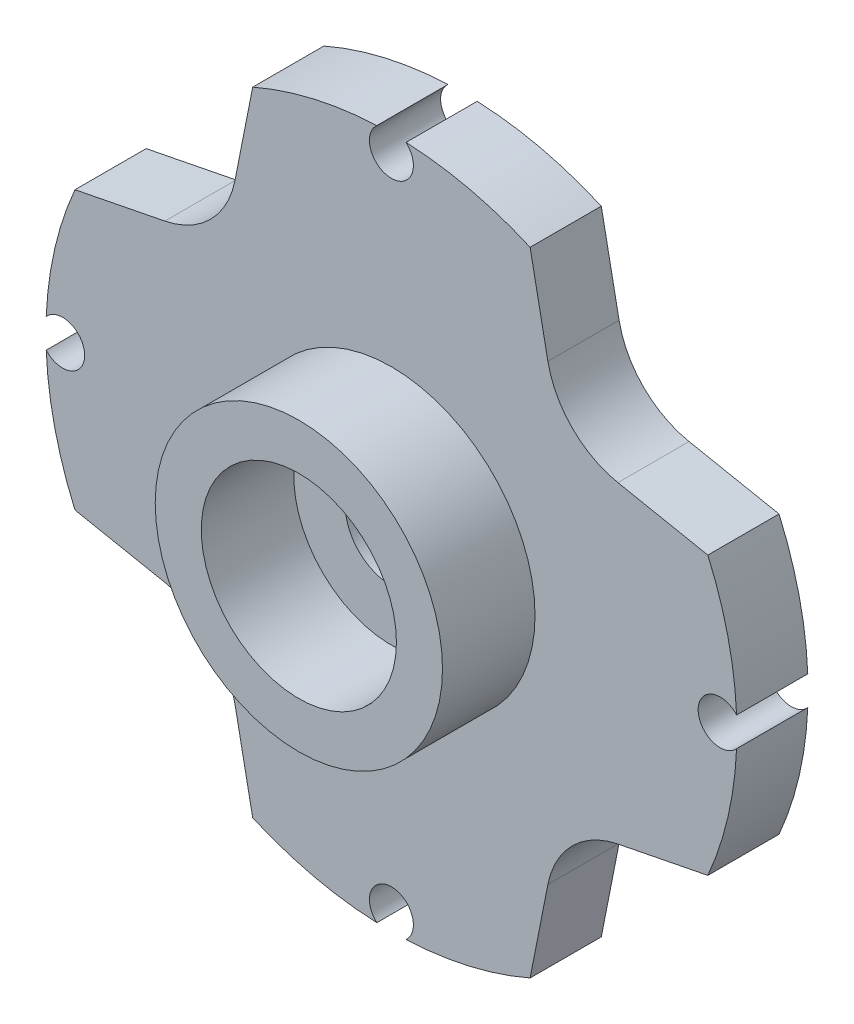
from build123d import *

# Parameters (mm, degrees)
BOSS_EXTRUDE1_DEPTH     = 1.7
CUT_EXTRUDE1_REACH      = 3.7
SKETCH2_R               = 1.1
SKETCH3_R               = 3.43
SKETCH3_R_2             = 2.33
BOSS_EXTRUDE2_DEPTH     = 2.21
SKETCH4_R               = 3.5
SKETCH4_R_2             = 2.95
BOSS_EXTRUDE3_DEPTH     = 0.51
SKETCH5_R               = 2.95
CUT_EXTRUDE2_DEPTH      = 1.1
CUT_EXTRUDE3_REACH      = 4.21
SKETCH6_R               = 0.525
SKETCH7_R               = 18.883041925
SKETCH7_R_2             = 8.25
CUT_EXTRUDE4_DEPTH      = 3.21
CUT_EXTRUDE4_DEPTH_BACK = 3.21


with BuildPart() as part:
    # Sketch1 → Boss-Extrude1 (new body)
    with BuildSketch(Plane.XY):
        with BuildLine():
            Line((5.409077957, 3.736708277), (13.762285951, 2.084772448))
            ThreePointArc((13.762285951, 2.084772448), (15.475148434, 0), (13.762285951, -2.084772448))
            Line((13.762285951, -2.084772448), (5.409077957, -3.736708277))
            ThreePointArc((5.409077957, -3.736708277), (4.318733201, -4.318733201), (3.736708277, -5.409077957))
            Line((3.736708277, -5.409077957), (2.084772448, -13.762285951))
            ThreePointArc((2.084772448, -13.762285951), (0, -15.475148434), (-2.084772448, -13.762285951))
            Line((-2.084772448, -13.762285951), (-3.736708277, -5.409077957))
            ThreePointArc((-3.736708277, -5.409077957), (-4.318733201, -4.318733201), (-5.409077957, -3.736708277))
            Line((-5.409077957, -3.736708277), (-13.762285951, -2.084772448))
            ThreePointArc((-13.762285951, -2.084772448), (-15.475148434, 0), (-13.762285951, 2.084772448))
            Line((-13.762285951, 2.084772448), (-5.409077957, 3.736708277))
            ThreePointArc((-5.409077957, 3.736708277), (-4.318733201, 4.318733201), (-3.736708277, 5.409077957))
            Line((-3.736708277, 5.409077957), (-2.084772448, 13.762285951))
            ThreePointArc((-2.084772448, 13.762285951), (0, 15.475148434), (2.084772448, 13.762285951))
            Line((2.084772448, 13.762285951), (3.736708277, 5.409077957))
            ThreePointArc((3.736708277, 5.409077957), (4.318733201, 4.318733201), (5.409077957, 3.736708277))
        make_face()
    extrude(amount=BOSS_EXTRUDE1_DEPTH)

    # Sketch2 → Cut-Extrude1 (cut, up to next)
    with BuildSketch(Plane.XY.offset(1.7), mode=Mode.PRIVATE) as cut_extrude1_sk1:
        Circle(SKETCH2_R)
    cut_extrude1_tool1 = extrude(cut_extrude1_sk1.sketch, amount=-CUT_EXTRUDE1_REACH, mode=Mode.PRIVATE) & part.part
    add(cut_extrude1_tool1.solids().sort_by_distance((0, 0, 1.7))[0], mode=Mode.SUBTRACT)

    # Sketch3 → Boss-Extrude2 (add)
    with BuildSketch(Plane.XY.offset(1.7)):
        Circle(SKETCH3_R)
        Circle(SKETCH3_R_2, mode=Mode.SUBTRACT)
    extrude(amount=BOSS_EXTRUDE2_DEPTH)

    # Sketch4 → Boss-Extrude3 (add)
    with BuildSketch(Plane(origin=(0, 0, 0), x_dir=(-1, 0, 0), z_dir=(0, 0, -1))):
        Circle(SKETCH4_R)
        Circle(SKETCH4_R_2, mode=Mode.SUBTRACT)
    extrude(amount=BOSS_EXTRUDE3_DEPTH)

    # Sketch5 → Cut-Extrude2 (cut)
    with BuildSketch(Plane(origin=(0, 0, -0.51), x_dir=(-1, 0, 0), z_dir=(0, 0, -1))):
        Circle(SKETCH5_R)
    extrude(amount=-CUT_EXTRUDE2_DEPTH, mode=Mode.SUBTRACT)

    # Sketch6 → Cut-Extrude3 (cut, up to next)
    with BuildSketch(Plane.XY.offset(1.7), mode=Mode.PRIVATE) as cut_extrude3_sk1:
        with Locations((0, 13.35)):
            Circle(SKETCH6_R)
    cut_extrude3_tool1 = extrude(cut_extrude3_sk1.sketch, amount=-CUT_EXTRUDE3_REACH, mode=Mode.PRIVATE) & part.part
    add(cut_extrude3_tool1.solids().sort_by_distance((0, 13.35, 1.7))[0], mode=Mode.SUBTRACT)
    # Sketch6 → Cut-Extrude3 (cut, up to next)
    with BuildSketch(Plane.XY.offset(1.7), mode=Mode.PRIVATE) as cut_extrude3_sk2:
        with Locations((0, 10.6)):
            Circle(SKETCH6_R)
    cut_extrude3_tool2 = extrude(cut_extrude3_sk2.sketch, amount=-CUT_EXTRUDE3_REACH, mode=Mode.PRIVATE) & part.part
    add(cut_extrude3_tool2.solids().sort_by_distance((0, 10.6, 1.7))[0], mode=Mode.SUBTRACT)
    # Sketch6 → Cut-Extrude3 (cut, up to next)
    with BuildSketch(Plane.XY.offset(1.7), mode=Mode.PRIVATE) as cut_extrude3_sk3:
        with Locations((0, 7.85)):
            Circle(SKETCH6_R)
    cut_extrude3_tool3 = extrude(cut_extrude3_sk3.sketch, amount=-CUT_EXTRUDE3_REACH, mode=Mode.PRIVATE) & part.part
    add(cut_extrude3_tool3.solids().sort_by_distance((0, 7.85, 1.7))[0], mode=Mode.SUBTRACT)
    # Sketch6 → Cut-Extrude3 (cut, up to next)
    with BuildSketch(Plane.XY.offset(1.7), mode=Mode.PRIVATE) as cut_extrude3_sk4:
        with Locations((13.35, 0)):
            Circle(SKETCH6_R)
    cut_extrude3_tool4 = extrude(cut_extrude3_sk4.sketch, amount=-CUT_EXTRUDE3_REACH, mode=Mode.PRIVATE) & part.part
    add(cut_extrude3_tool4.solids().sort_by_distance((13.35, 0, 1.7))[0], mode=Mode.SUBTRACT)
    # Sketch6 → Cut-Extrude3 (cut, up to next)
    with BuildSketch(Plane.XY.offset(1.7), mode=Mode.PRIVATE) as cut_extrude3_sk5:
        with Locations((10.6, 0)):
            Circle(SKETCH6_R)
    cut_extrude3_tool5 = extrude(cut_extrude3_sk5.sketch, amount=-CUT_EXTRUDE3_REACH, mode=Mode.PRIVATE) & part.part
    add(cut_extrude3_tool5.solids().sort_by_distance((10.6, 0, 1.7))[0], mode=Mode.SUBTRACT)
    # Sketch6 → Cut-Extrude3 (cut, up to next)
    with BuildSketch(Plane.XY.offset(1.7), mode=Mode.PRIVATE) as cut_extrude3_sk6:
        with Locations((7.85, 0)):
            Circle(SKETCH6_R)
    cut_extrude3_tool6 = extrude(cut_extrude3_sk6.sketch, amount=-CUT_EXTRUDE3_REACH, mode=Mode.PRIVATE) & part.part
    add(cut_extrude3_tool6.solids().sort_by_distance((7.85, 0, 1.7))[0], mode=Mode.SUBTRACT)
    # Sketch6 → Cut-Extrude3 (cut, up to next)
    with BuildSketch(Plane.XY.offset(1.7), mode=Mode.PRIVATE) as cut_extrude3_sk7:
        with Locations((0, -13.35)):
            Circle(SKETCH6_R)
    cut_extrude3_tool7 = extrude(cut_extrude3_sk7.sketch, amount=-CUT_EXTRUDE3_REACH, mode=Mode.PRIVATE) & part.part
    add(cut_extrude3_tool7.solids().sort_by_distance((0, -13.35, 1.7))[0], mode=Mode.SUBTRACT)
    # Sketch6 → Cut-Extrude3 (cut, up to next)
    with BuildSketch(Plane.XY.offset(1.7), mode=Mode.PRIVATE) as cut_extrude3_sk8:
        with Locations((0, -10.6)):
            Circle(SKETCH6_R)
    cut_extrude3_tool8 = extrude(cut_extrude3_sk8.sketch, amount=-CUT_EXTRUDE3_REACH, mode=Mode.PRIVATE) & part.part
    add(cut_extrude3_tool8.solids().sort_by_distance((0, -10.6, 1.7))[0], mode=Mode.SUBTRACT)
    # Sketch6 → Cut-Extrude3 (cut, up to next)
    with BuildSketch(Plane.XY.offset(1.7), mode=Mode.PRIVATE) as cut_extrude3_sk9:
        with Locations((0, -7.85)):
            Circle(SKETCH6_R)
    cut_extrude3_tool9 = extrude(cut_extrude3_sk9.sketch, amount=-CUT_EXTRUDE3_REACH, mode=Mode.PRIVATE) & part.part
    add(cut_extrude3_tool9.solids().sort_by_distance((0, -7.85, 1.7))[0], mode=Mode.SUBTRACT)
    # Sketch6 → Cut-Extrude3 (cut, up to next)
    with BuildSketch(Plane.XY.offset(1.7), mode=Mode.PRIVATE) as cut_extrude3_sk10:
        with Locations((-13.35, 0)):
            Circle(SKETCH6_R)
    cut_extrude3_tool10 = extrude(cut_extrude3_sk10.sketch, amount=-CUT_EXTRUDE3_REACH, mode=Mode.PRIVATE) & part.part
    add(cut_extrude3_tool10.solids().sort_by_distance((-13.35, 0, 1.7))[0], mode=Mode.SUBTRACT)
    # Sketch6 → Cut-Extrude3 (cut, up to next)
    with BuildSketch(Plane.XY.offset(1.7), mode=Mode.PRIVATE) as cut_extrude3_sk11:
        with Locations((-10.6, 0)):
            Circle(SKETCH6_R)
    cut_extrude3_tool11 = extrude(cut_extrude3_sk11.sketch, amount=-CUT_EXTRUDE3_REACH, mode=Mode.PRIVATE) & part.part
    add(cut_extrude3_tool11.solids().sort_by_distance((-10.6, 0, 1.7))[0], mode=Mode.SUBTRACT)
    # Sketch6 → Cut-Extrude3 (cut, up to next)
    with BuildSketch(Plane.XY.offset(1.7), mode=Mode.PRIVATE) as cut_extrude3_sk12:
        with Locations((-7.85, 0)):
            Circle(SKETCH6_R)
    cut_extrude3_tool12 = extrude(cut_extrude3_sk12.sketch, amount=-CUT_EXTRUDE3_REACH, mode=Mode.PRIVATE) & part.part
    add(cut_extrude3_tool12.solids().sort_by_distance((-7.85, 0, 1.7))[0], mode=Mode.SUBTRACT)

    # Sketch7 → Cut-Extrude4 (cut, two sides)
    with BuildSketch(Plane.XY.offset(1.7)) as cut_extrude4_sk:
        Circle(SKETCH7_R)
        Circle(SKETCH7_R_2, mode=Mode.SUBTRACT)
    extrude(amount=CUT_EXTRUDE4_DEPTH, mode=Mode.SUBTRACT)
    extrude(cut_extrude4_sk.sketch, amount=-CUT_EXTRUDE4_DEPTH_BACK, mode=Mode.SUBTRACT)


solid = part.part
